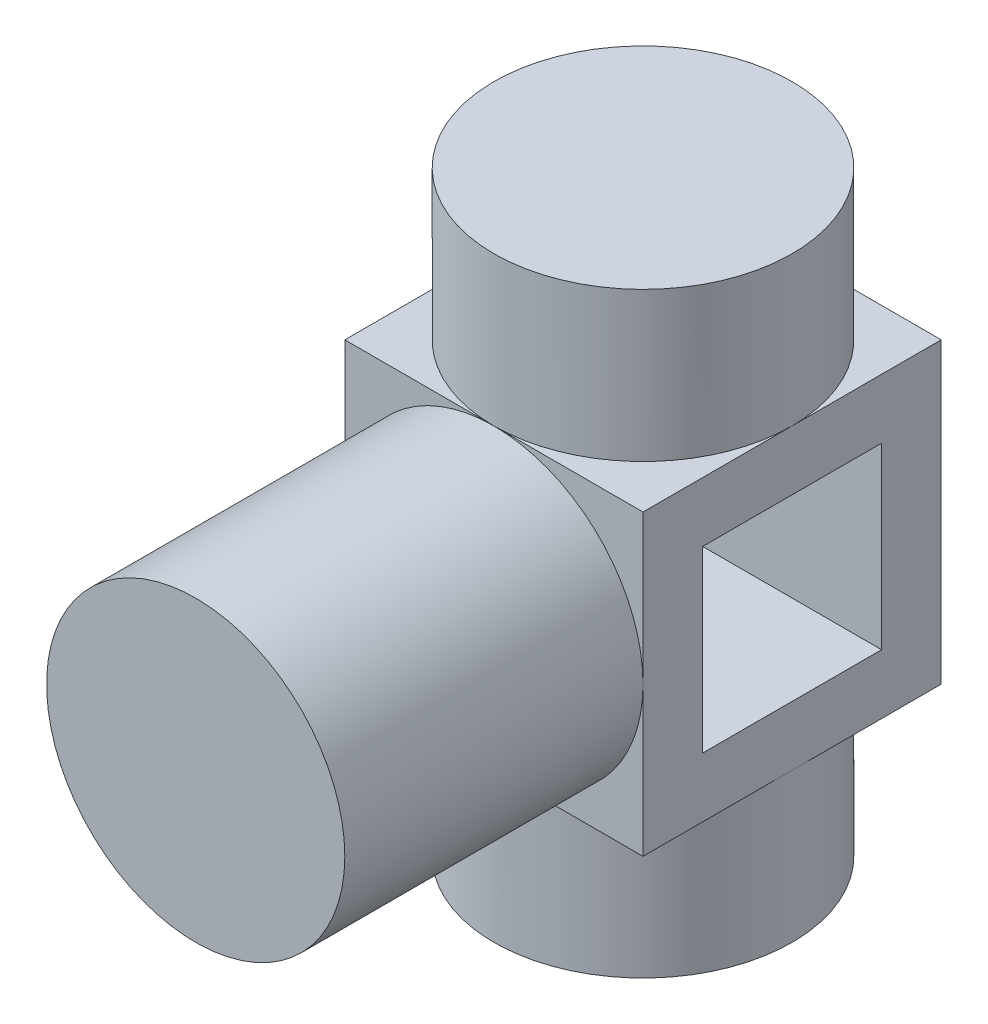
from build123d import *

# Parameters (mm, degrees)
SKETCH1_W           = 50
SKETCH1_H           = 50
BOSS_EXTRUDE1_DEPTH = 100
SKETCH2_W           = 50
SKETCH2_H           = 50
BOSS_EXTRUDE2_DEPTH = 50
CUT_EXTRUDE1_DEPTH  = 50
CUT_EXTRUDE3_DEPTH  = 25
CUT_EXTRUDE4_DEPTH  = 25
CUT_EXTRUDE5_REACH  = 52
SKETCH6_W           = 30
SKETCH6_H           = 30


with BuildPart() as part:
    # Sketch1 → Boss-Extrude1 (new body)
    with BuildSketch(Plane(origin=(0, 0, 0), x_dir=(1, 0, 0), z_dir=(0, 1, 0))):
        Rectangle(SKETCH1_W, SKETCH1_H)
    extrude(amount=BOSS_EXTRUDE1_DEPTH)

    # Sketch2 → Boss-Extrude2 (add)
    with BuildSketch(Plane.XY.offset(25)):
        with Locations((0, 50)):
            Rectangle(SKETCH2_W, SKETCH2_H)
    extrude(amount=BOSS_EXTRUDE2_DEPTH)

    # Sketch3 → Cut-Extrude1 (cut)
    with BuildSketch(Plane.XY.offset(75)):
        with BuildLine():
            Line((8.4e-08, 75), (-25, 75))
            Line((-25, 75), (-25, 49.999999966))
            ThreePointArc((-25, 49.999999966), (-17.677669512, 67.677669547), (8.4e-08, 75))
        make_face()
        with BuildLine():
            Line((25, 75), (8.4e-08, 75))
            ThreePointArc((8.4e-08, 75), (17.677669559, 67.6776695), (25, 50))
            Line((25, 50), (25, 75))
        make_face()
        with BuildLine():
            Line((25, 25), (25, 50))
            ThreePointArc((25, 50), (17.677669509, 32.32233045), (-5.8e-08, 25))
            Line((-5.8e-08, 25), (25, 25))
        make_face()
        with BuildLine():
            ThreePointArc((-5.8e-08, 25), (-17.677669538, 32.322330479), (-25, 49.999999966))
            Line((-25, 49.999999966), (-25, 25))
            Line((-25, 25), (-5.8e-08, 25))
        make_face()
    extrude(amount=-CUT_EXTRUDE1_DEPTH, mode=Mode.SUBTRACT)

    # Sketch4 → Cut-Extrude3 (cut)
    with BuildSketch(Plane(origin=(0, 100, 0), x_dir=(1, 0, 0), z_dir=(0, 1, 0))):
        with BuildLine():
            ThreePointArc((0, -25), (-17.67766954, -17.677669519), (-25, 3e-08))
            Line((-25, 3e-08), (-25, -25))
            Line((-25, -25), (0, -25))
        make_face()
        with BuildLine():
            Line((0, 25), (-25, 25))
            Line((-25, 25), (-25, 3e-08))
            ThreePointArc((-25, 3e-08), (-17.677669519, 17.67766954), (0, 25))
        make_face()
        with BuildLine():
            Line((25, 25), (0, 25))
            ThreePointArc((0, 25), (17.67766953, 17.67766953), (25, 0))
            Line((25, 0), (25, 25))
        make_face()
        with BuildLine():
            Line((25, -25), (25, 0))
            ThreePointArc((25, 0), (17.67766953, -17.67766953), (0, -25))
            Line((0, -25), (25, -25))
        make_face()
    extrude(amount=-CUT_EXTRUDE3_DEPTH, mode=Mode.SUBTRACT)

    # Sketch5 → Cut-Extrude4 (cut)
    with BuildSketch(Plane.XZ):
        with BuildLine():
            Line((-2e-08, 25), (-25, 25))
            Line((-25, 25), (-25, 1e-09))
            ThreePointArc((-25, 1e-09), (-17.677669536, 17.677669523), (-2e-08, 25))
        make_face()
        with BuildLine():
            Line((25, 25), (-2e-08, 25))
            ThreePointArc((-2e-08, 25), (17.677669523, 17.677669537), (25, 0))
            Line((25, 0), (25, 25))
        make_face()
        with BuildLine():
            Line((25, -25), (25, 0))
            ThreePointArc((25, 0), (17.67766952, -17.677669539), (-2.6e-08, -25))
            Line((-2.6e-08, -25), (25, -25))
        make_face()
        with BuildLine():
            ThreePointArc((-2.6e-08, -25), (-17.677669539, -17.67766952), (-25, 1e-09))
            Line((-25, 1e-09), (-25, -25))
            Line((-25, -25), (-2.6e-08, -25))
        make_face()
    extrude(amount=-CUT_EXTRUDE4_DEPTH, mode=Mode.SUBTRACT)

    # Sketch6 → Cut-Extrude5 (cut, up to next)
    with BuildSketch(Plane.ZY.offset(25), mode=Mode.PRIVATE) as cut_extrude5_sk1:
        with Locations((0, 50)):
            Rectangle(SKETCH6_W, SKETCH6_H)
    cut_extrude5_tool1 = extrude(cut_extrude5_sk1.sketch, amount=-CUT_EXTRUDE5_REACH, mode=Mode.PRIVATE) & part.part
    add(cut_extrude5_tool1.solids().sort_by_distance((-25, 50, 0))[0], mode=Mode.SUBTRACT)


solid = part.part
